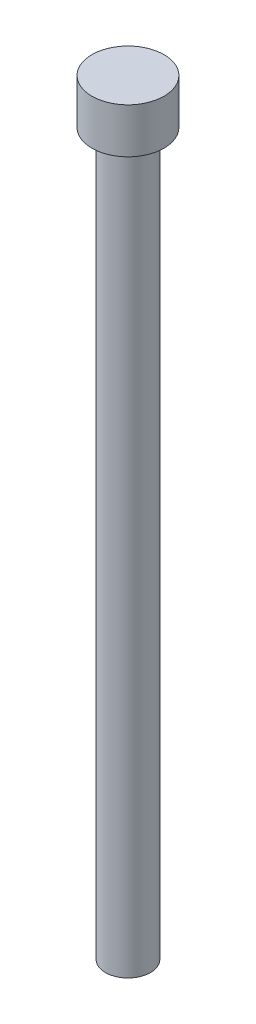
from build123d import *

# Parameters (mm, degrees)
SKETCH1_R           = 3.175
BOSS_EXTRUDE1_DEPTH = 101.6
SKETCH2_R           = 5.08
BOSS_EXTRUDE2_DEPTH = 6.35


with BuildPart() as part:
    # Sketch1 → Boss-Extrude1 (new body)
    with BuildSketch(Plane(origin=(0, 0, 0), x_dir=(1, 0, 0), z_dir=(0, 1, 0))):
        Circle(SKETCH1_R)
    extrude(amount=BOSS_EXTRUDE1_DEPTH)

    # Sketch2 → Boss-Extrude2 (add)
    with BuildSketch(Plane(origin=(0, 101.6, 0), x_dir=(1, 0, 0), z_dir=(0, 1, 0))):
        Circle(SKETCH2_R)
    extrude(amount=BOSS_EXTRUDE2_DEPTH)


solid = part.part
